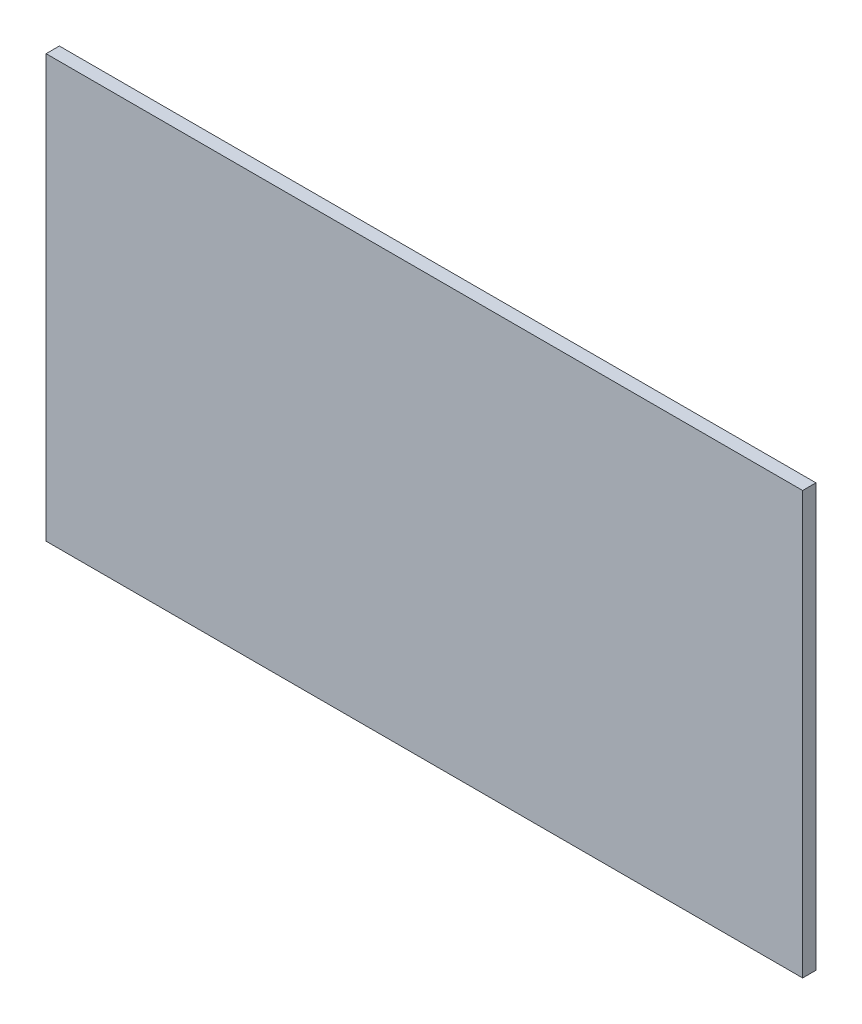
from build123d import *

# Parameters (mm, degrees)
SKETCH1_W           = 1025
SKETCH1_H           = 572
BOSS_EXTRUDE1_DEPTH = 18


with BuildPart() as part:
    # Sketch1 → Boss-Extrude1 (new body)
    with BuildSketch(Plane.XY):
        Rectangle(SKETCH1_W, SKETCH1_H)
    extrude(amount=BOSS_EXTRUDE1_DEPTH)


solid = part.part
